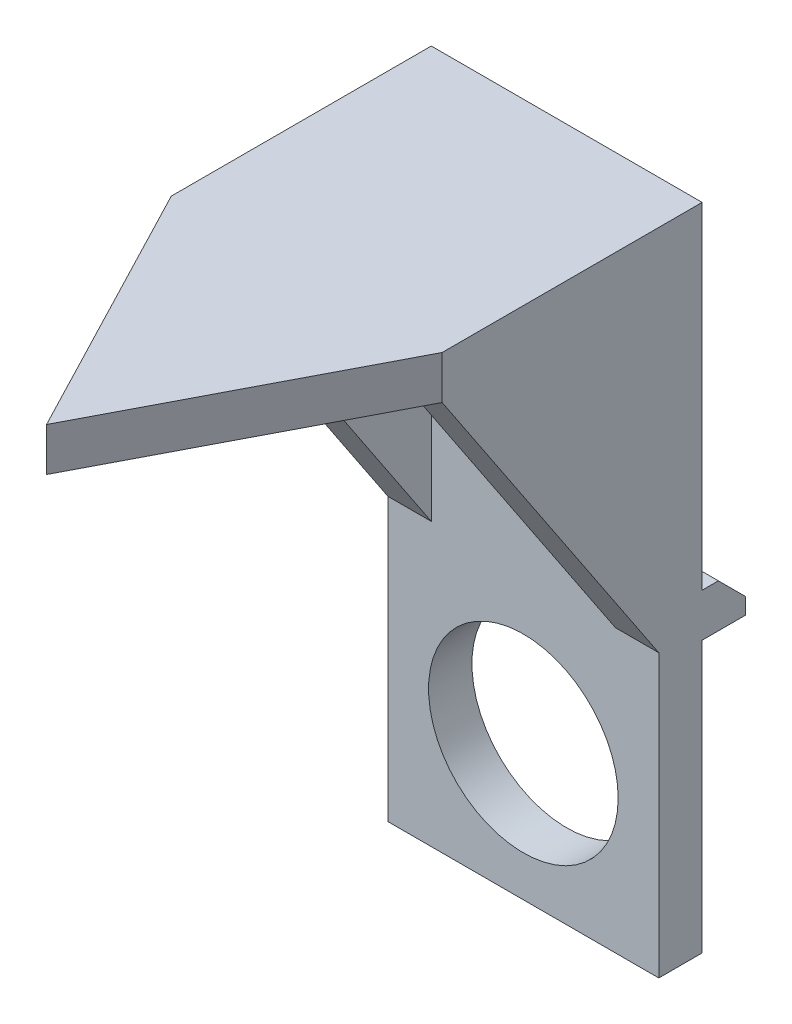
from build123d import *

# Parameters (mm, degrees)
SKETCH1_W           = 10
SKETCH1_H           = 24
BODY_DEPTH          = 1.6
SKETCH2_W           = 10
SKETCH2_H           = 1.6
BOSS_EXTRUDE2_DEPTH = 1.6
FIN_CHAMFER_SIZE    = 1
SKETCH3_R           = 3.5
HOLE_DEPTH          = 4.2
FIN_DEPTH           = 17.604910635
SIDE_CUT_DEPTH      = 11
TOP_CUT_DEPTH       = 2.6


with BuildPart() as part:
    # Sketch1 → Body (new body)
    with BuildSketch(Plane.XY):
        with Locations((0, 7)):
            Rectangle(SKETCH1_W, SKETCH1_H)
    extrude(amount=BODY_DEPTH)

    # Sketch2 → Boss-Extrude2 (add)
    with BuildSketch(Plane(origin=(0, 0, 0), x_dir=(-1, 0, 0), z_dir=(0, 0, -1))):
        with Locations((0, 5.8)):
            Rectangle(SKETCH2_W, SKETCH2_H)
    extrude(amount=BOSS_EXTRUDE2_DEPTH)

    # Fin Chamfer
    fin_chamfer_edges = [part.edges().sort_by_distance(p)[0] for p in [
        (0, 6.6, -1.6),
    ]]
    chamfer(fin_chamfer_edges, length=FIN_CHAMFER_SIZE)

    # Sketch3 → Hole (cut, through all)
    with BuildSketch(Plane.XY.offset(1.6)):
        Circle(SKETCH3_R)
    extrude(amount=-HOLE_DEPTH, mode=Mode.SUBTRACT)

    # Sketch4 → Fin (add)
    with BuildSketch(Plane.XY.offset(1.6)):
        Polygon((-5, 19), (-5, 5.4), (-3.4, 5.4), (-3.4, 17.4), (3.4, 17.4), (3.4, 5.4), (5, 5.4), (5, 19), align=None)
    extrude(amount=FIN_DEPTH)

    # Sketch5 → Side Cut (cut, through all)
    with BuildSketch(Plane(origin=(5, 0, 0), x_dir=(0, 0, -1), z_dir=(1, 0, 0))):
        Polygon((-1.6, 5.4), (-9.6, 5.4), (-19.204910635, 5.4), (-19.204910635, 17.4), (-9.6, 17.4), align=None)
    extrude(amount=-SIDE_CUT_DEPTH, mode=Mode.SUBTRACT)

    # Sketch7 → Top Cut (cut, through all)
    with BuildSketch(Plane.XZ.offset(-17.4)):
        Polygon((-5, 19.204910635), (-5, 9.6), (0, 19.204910635), align=None)
        Polygon((5, 19.204910635), (0, 19.204910635), (5, 9.6), align=None)
    extrude(amount=-TOP_CUT_DEPTH, mode=Mode.SUBTRACT)


solid = part.part
